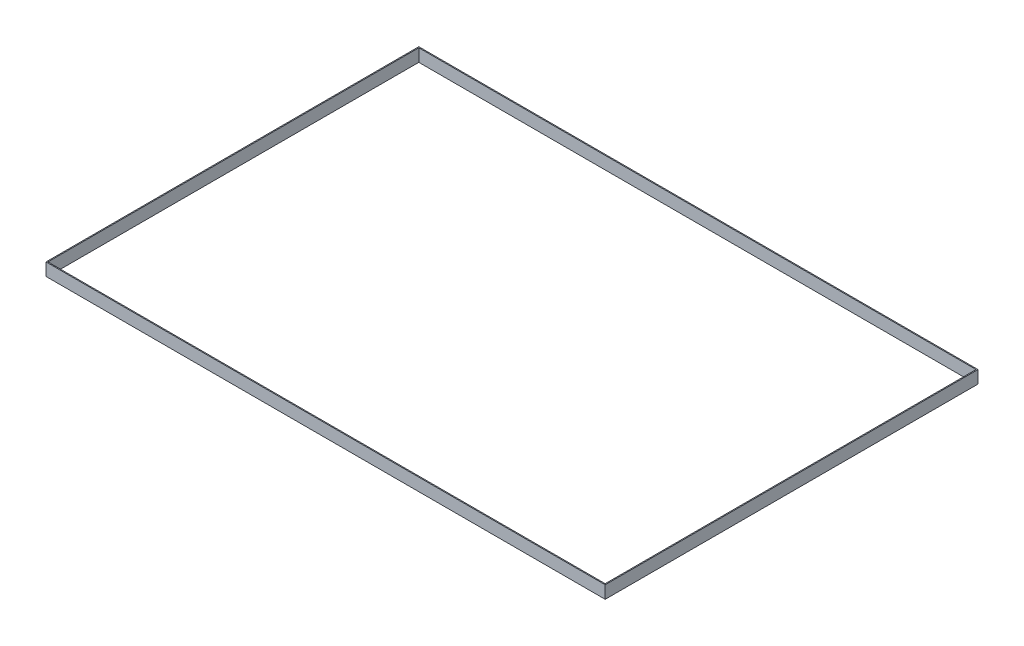
from build123d import *

# Parameters (mm, degrees)
SKETCH1_W           = 3657.6
SKETCH1_H           = 2438.4
BOSS_EXTRUDE1_DEPTH = 6.35
SKETCH3_W           = 3657.6
SKETCH3_H           = 2438.4
SKETCH3_W_2         = 3644.9
SKETCH3_H_2         = 2425.7
BOSS_EXTRUDE2_DEPTH = 76.2
SKETCH4_W           = 3644.9
SKETCH4_H           = 2425.7
CUT_EXTRUDE1_DEPTH  = 7.35


with BuildPart() as part:
    # Sketch1 → Boss-Extrude1 (new body)
    with BuildSketch(Plane(origin=(0, 0, 0), x_dir=(1, 0, 0), z_dir=(0, 1, 0))):
        with Locations((1828.8, 1219.2)):
            Rectangle(SKETCH1_W, SKETCH1_H)
    extrude(amount=BOSS_EXTRUDE1_DEPTH)

    # Sketch3 → Boss-Extrude2 (add)
    with BuildSketch(Plane(origin=(0, 6.35, 0), x_dir=(1, 0, 0), z_dir=(0, 1, 0))):
        with Locations((1828.8, 1219.2)):
            Rectangle(SKETCH3_W, SKETCH3_H)
        with Locations((1828.8, 1219.2)):
            Rectangle(SKETCH3_W_2, SKETCH3_H_2, mode=Mode.SUBTRACT)
    extrude(amount=BOSS_EXTRUDE2_DEPTH)

    # Sketch4 → Cut-Extrude1 (cut, through all)
    with BuildSketch(Plane(origin=(0, 6.35, 0), x_dir=(1, 0, 0), z_dir=(0, 1, 0))):
        with Locations((1828.8, 1219.2)):
            Rectangle(SKETCH4_W, SKETCH4_H)
    extrude(amount=-CUT_EXTRUDE1_DEPTH, mode=Mode.SUBTRACT)


solid = part.part
